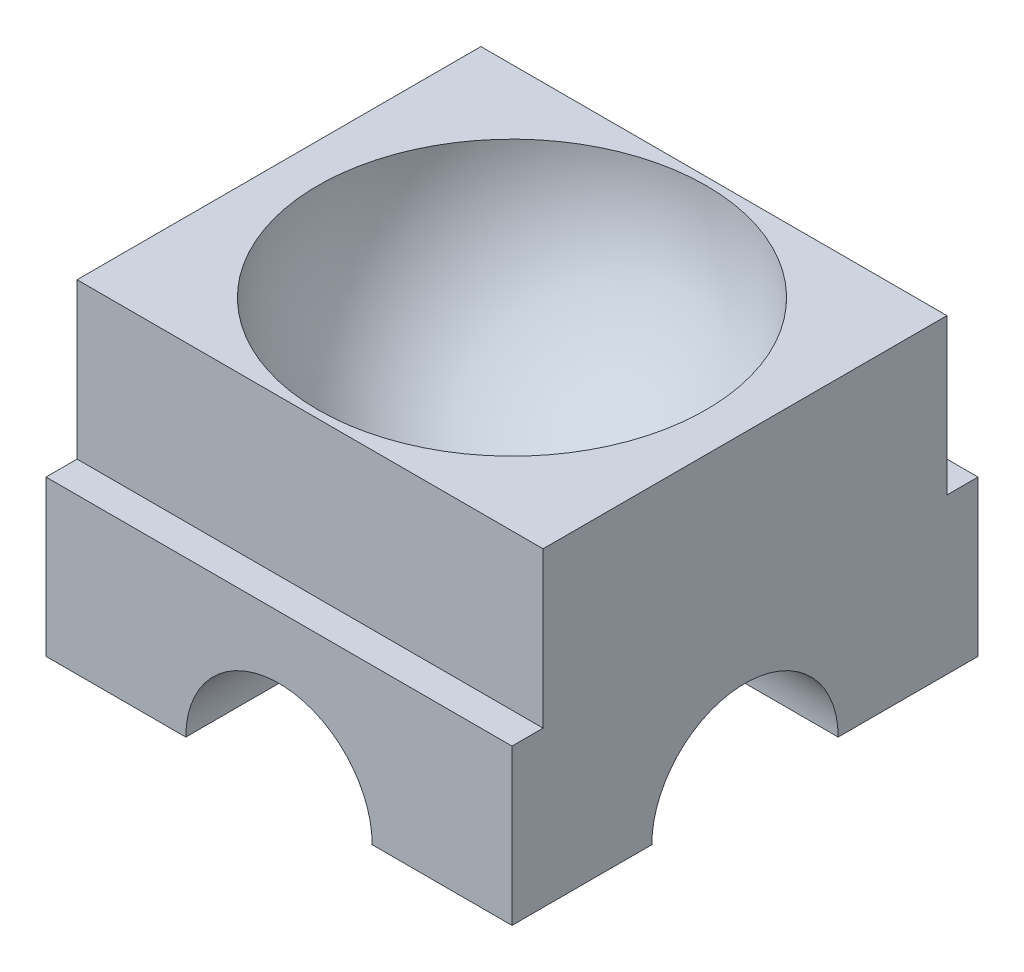
from build123d import *

# Parameters (mm, degrees)
SKETCH2_W               = 30
SKETCH2_H               = 30
BOSS_EXTRUDE1_DEPTH     = 20
SKETCH3_R               = 6
CUT_EXTRUDE2_DEPTH      = 1
CUT_EXTRUDE2_DEPTH_BACK = 31
SKETCH4_R               = 6
CUT_EXTRUDE3_DEPTH      = 1
CUT_EXTRUDE3_DEPTH_BACK = 31
SKETCH7_R               = 3.75
CUT_EXTRUDE4_DEPTH      = 21
SKETCH8_W               = 30
SKETCH8_H               = 10
CUT_EXTRUDE6_DEPTH      = 2
SKETCH9_W               = 30
SKETCH9_H               = 10
CUT_EXTRUDE7_DEPTH      = 2


with BuildPart() as part:
    # Sketch2 → Boss-Extrude1 (new body)
    with BuildSketch(Plane(origin=(0, 0, 0), x_dir=(1, 0, 0), z_dir=(0, 1, 0))):
        Rectangle(SKETCH2_W, SKETCH2_H)
    extrude(amount=BOSS_EXTRUDE1_DEPTH)

    # Sketch3 → Cut-Extrude2 (cut, two sides)
    with BuildSketch(Plane.XY.offset(15)) as cut_extrude2_sk:
        Circle(SKETCH3_R)
    extrude(amount=CUT_EXTRUDE2_DEPTH, mode=Mode.SUBTRACT)
    extrude(cut_extrude2_sk.sketch, amount=-CUT_EXTRUDE2_DEPTH_BACK, mode=Mode.SUBTRACT)

    # Sketch4 → Cut-Extrude3 (cut, two sides)
    with BuildSketch(Plane(origin=(15, 0, 0), x_dir=(0, 0, -1), z_dir=(1, 0, 0))) as cut_extrude3_sk:
        Circle(SKETCH4_R)
    extrude(amount=CUT_EXTRUDE3_DEPTH, mode=Mode.SUBTRACT)
    extrude(cut_extrude3_sk.sketch, amount=-CUT_EXTRUDE3_DEPTH_BACK, mode=Mode.SUBTRACT)

    # Sketch5 → Cut-Revolve1 (revolve, cut)
    with BuildSketch(Plane(origin=(0, 20, 0), x_dir=(1, 0, 0), z_dir=(0, 1, 0))):
        with BuildLine():
            Line((12.5, 0), (-12.5, 0))
            ThreePointArc((-12.5, 0), (0, 12.5), (12.5, 0))
        make_face()
    revolve(axis=Axis((12.5, 20, 0), (-1, 0, 0)), mode=Mode.SUBTRACT)

    # Sketch7 → Cut-Extrude4 (cut, through all)
    with BuildSketch(Plane(origin=(0, 20, 0), x_dir=(1, 0, 0), z_dir=(0, 1, 0))):
        Circle(SKETCH7_R)
    extrude(amount=-CUT_EXTRUDE4_DEPTH, mode=Mode.SUBTRACT)

    # Sketch8 → Cut-Extrude6 (cut)
    with BuildSketch(Plane.XY.offset(15)):
        with Locations((0, 15)):
            Rectangle(SKETCH8_W, SKETCH8_H)
    extrude(amount=-CUT_EXTRUDE6_DEPTH, mode=Mode.SUBTRACT)

    # Sketch9 → Cut-Extrude7 (cut)
    with BuildSketch(Plane(origin=(0, 0, -15), x_dir=(-1, 0, 0), z_dir=(0, 0, -1))):
        with Locations((0, 15)):
            Rectangle(SKETCH9_W, SKETCH9_H)
    extrude(amount=-CUT_EXTRUDE7_DEPTH, mode=Mode.SUBTRACT)


solid = part.part
